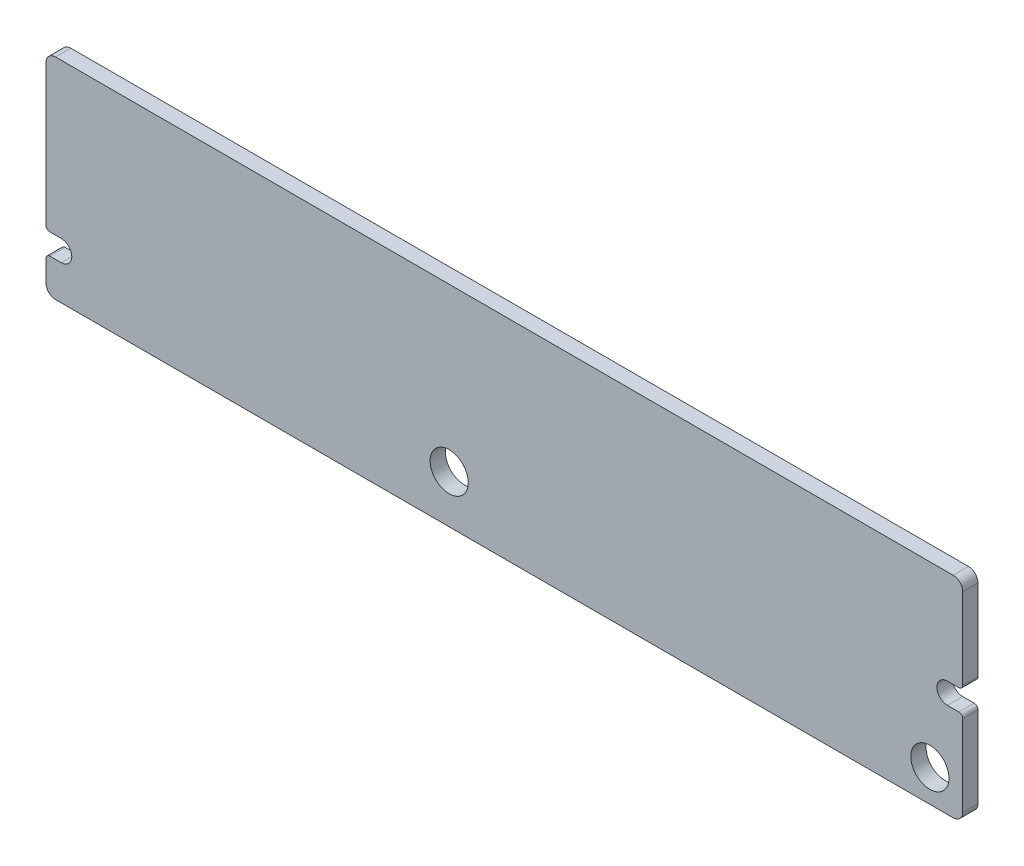
from build123d import *

# Parameters (mm, degrees)
BOSS_EXTRUDE1_DEPTH = 0.8
SKETCH2_W           = 2.797017598
SKETCH2_H           = 3.051291925
SKETCH2_W_2         = 4.216715925
SKETCH2_H_2         = 2.39441658
BOSS_EXTRUDE2_DEPTH = 1.5


with BuildPart() as part:
    # Sketch1 → Boss-Extrude1 (new body)
    with BuildSketch(Plane.XY.offset(-3.67)):
        with BuildLine():
            Line((-47.1, 0.52), (-46.5, 0.52))
            ThreePointArc((-46.5, 0.52), (-45.95, -0.03), (-46.5, -0.58))
            Line((-46.5, -0.58), (-47.1, -0.58))
            ThreePointArc((-47.1, -0.58), (-47.241421356, -0.638578644), (-47.3, -0.78))
            Line((-47.3, -0.78), (-47.3, -1.9))
            ThreePointArc((-47.3, -1.9), (-47.153553391, -2.253553391), (-46.8, -2.4))
            Line((-46.8, -2.4), (0.2, -2.4))
            ThreePointArc((0.2, -2.4), (0.553553391, -2.253553391), (0.7, -1.9))
            Line((0.7, -1.9), (0.7, 2.35))
            ThreePointArc((0.7, 2.35), (0.641421356, 2.491421356), (0.5, 2.55))
            Line((0.5, 2.55), (-0.1, 2.55))
            ThreePointArc((-0.1, 2.55), (-0.65, 3.1), (-0.1, 3.65))
            Line((-0.1, 3.65), (0.5, 3.65))
            ThreePointArc((0.5, 3.65), (0.641421356, 3.708578644), (0.7, 3.85))
            Line((0.7, 3.85), (0.7, 8.1))
            ThreePointArc((0.7, 8.1), (0.553553391, 8.453553391), (0.2, 8.6))
            Line((0.2, 8.6), (-46.8, 8.6))
            ThreePointArc((-46.8, 8.6), (-47.153553391, 8.453553391), (-47.3, 8.1))
            Line((-47.3, 8.1), (-47.3, 0.72))
            ThreePointArc((-47.3, 0.72), (-47.241421356, 0.578578644), (-47.1, 0.52))
        make_face()
        with BuildLine():
            ThreePointArc((-2.02, -0.72), (-1.02, -1.72), (-0.02, -0.72))
            ThreePointArc((-0.02, -0.72), (-1.02, 0.28), (-2.02, -0.72))
        make_face(mode=Mode.SUBTRACT)
        with BuildLine():
            ThreePointArc((-27.19, 0.1), (-26.19, -0.9), (-25.19, 0.1))
            ThreePointArc((-25.19, 0.1), (-26.19, 1.1), (-27.19, 0.1))
        make_face(mode=Mode.SUBTRACT)
    extrude(amount=-BOSS_EXTRUDE1_DEPTH)

    # Sketch2 → Boss-Extrude2 (add)
    with BuildSketch(Plane(origin=(0, 0, -4.47), x_dir=(-1, 0, 0), z_dir=(0, 0, -1))):
        with Locations((21.254561383, 2.553733594)):
            Rectangle(SKETCH2_W, SKETCH2_H)
        with Locations((28.448405888, 2.564328357)):
            Rectangle(SKETCH2_W_2, SKETCH2_H_2)
    extrude(amount=BOSS_EXTRUDE2_DEPTH)


solid = part.part
